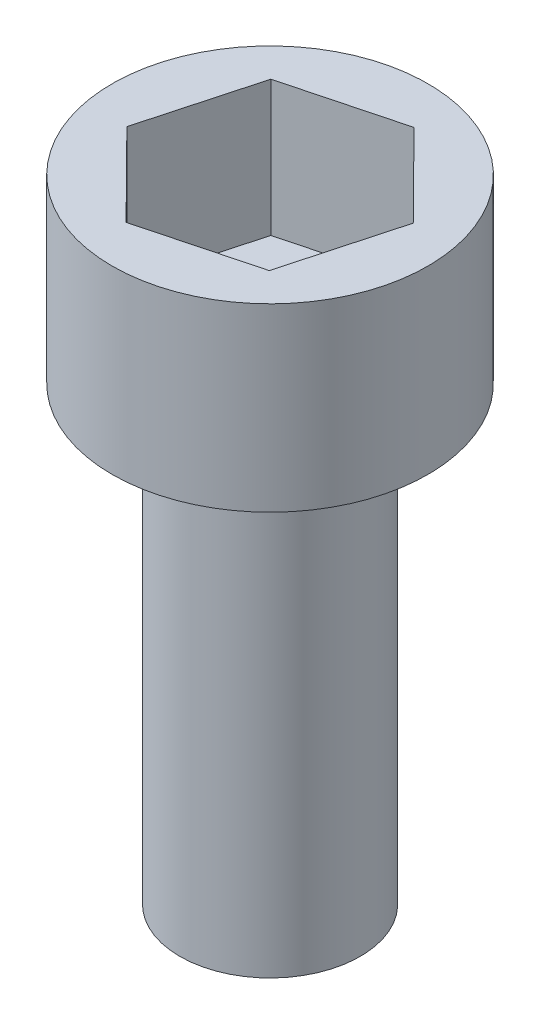
from build123d import *

# Parameters (mm, degrees)
SKETCH1_R           = 2
BOSS_EXTRUDE1_DEPTH = 10
SKETCH2_R           = 3.5
BOSS_EXTRUDE2_DEPTH = 4
CUT_EXTRUDE1_DEPTH  = 3


with BuildPart() as part:
    # Sketch1 → Boss-Extrude1 (new body)
    with BuildSketch(Plane(origin=(0, 0, 0), x_dir=(1, 0, 0), z_dir=(0, 1, 0))):
        Circle(SKETCH1_R)
    extrude(amount=BOSS_EXTRUDE1_DEPTH)

    # Sketch2 → Boss-Extrude2 (add)
    with BuildSketch(Plane(origin=(0, 10, 0), x_dir=(1, 0, 0), z_dir=(0, 1, 0))):
        Circle(SKETCH2_R)
    extrude(amount=BOSS_EXTRUDE2_DEPTH)

    # Sketch3 → Cut-Extrude1 (cut)
    with BuildSketch(Plane(origin=(0, 14, 0), x_dir=(1, 0, 0), z_dir=(0, 1, 0))):
        Polygon((2.512683193, 0.66062332), (0.684225019, 2.506359137), (-1.828458174, 1.845735817), (-2.512683193, -0.66062332), (-0.684225019, -2.506359137), (1.828458174, -1.845735817), align=None)
    extrude(amount=-CUT_EXTRUDE1_DEPTH, mode=Mode.SUBTRACT)


solid = part.part
